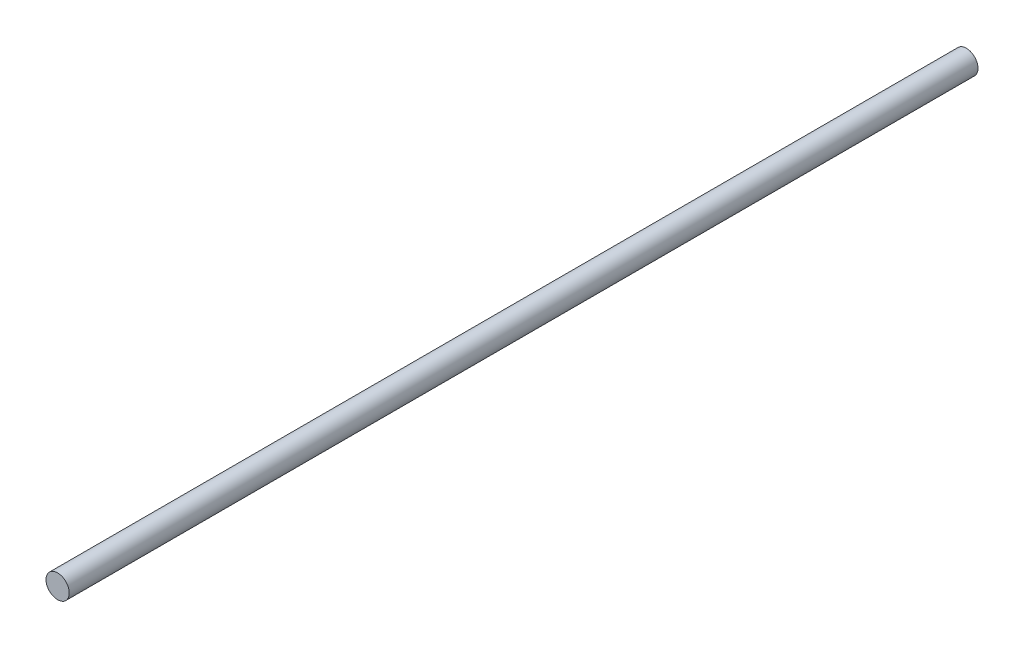
from build123d import *

# Parameters (mm, degrees)
SKETCH1_R           = 4
BOSS_EXTRUDE1_DEPTH = 312.45


with BuildPart() as part:
    # Sketch1 → Boss-Extrude1 (new body)
    with BuildSketch(Plane.XY):
        Circle(SKETCH1_R)
    extrude(amount=BOSS_EXTRUDE1_DEPTH)


solid = part.part
